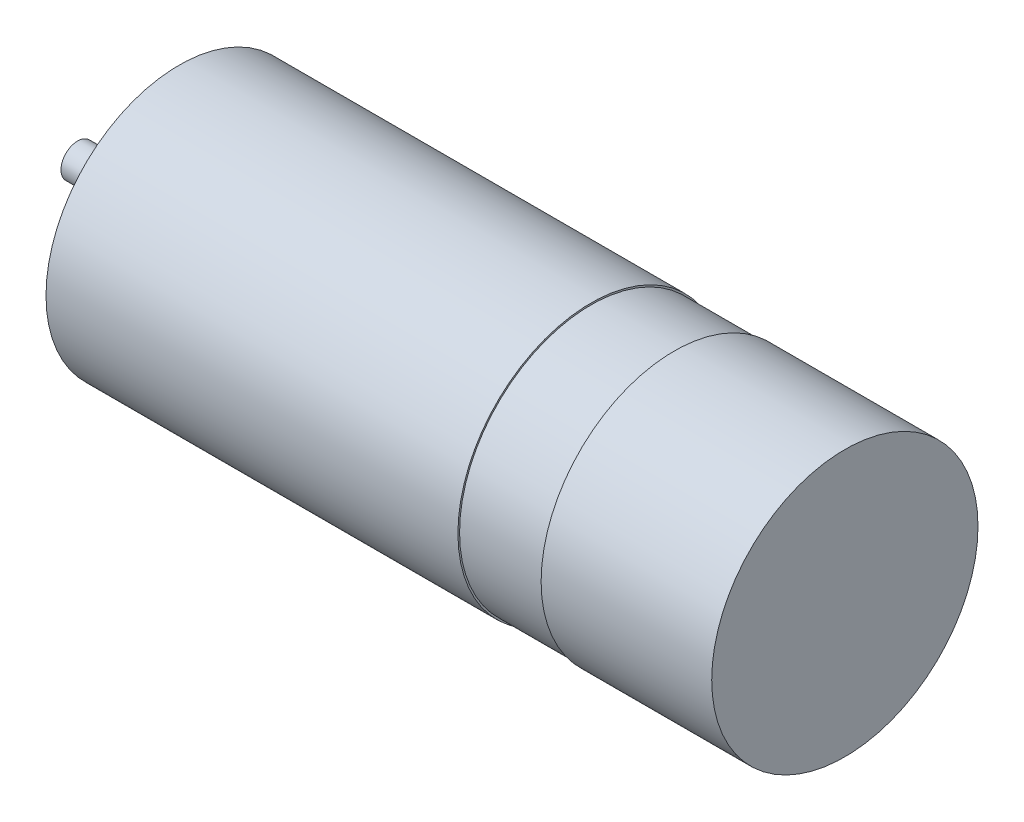
from build123d import *


with BuildPart() as part:
    # Sketch2 → Revolve1 (revolve)
    with BuildSketch(Plane.XY):
        Polygon((0, 0), (46.1, 0), (46.1, 8), (35.85, 8), (35.85, 7.9), (30.85, 7.9), (30.85, 8), (6.1, 8), (6.1, 4.5), (5.1, 4.5), (5.1, 1), (0, 1), align=None)
    revolve(axis=Axis((0, 0, 0), (1, 0, 0)))


solid = part.part
